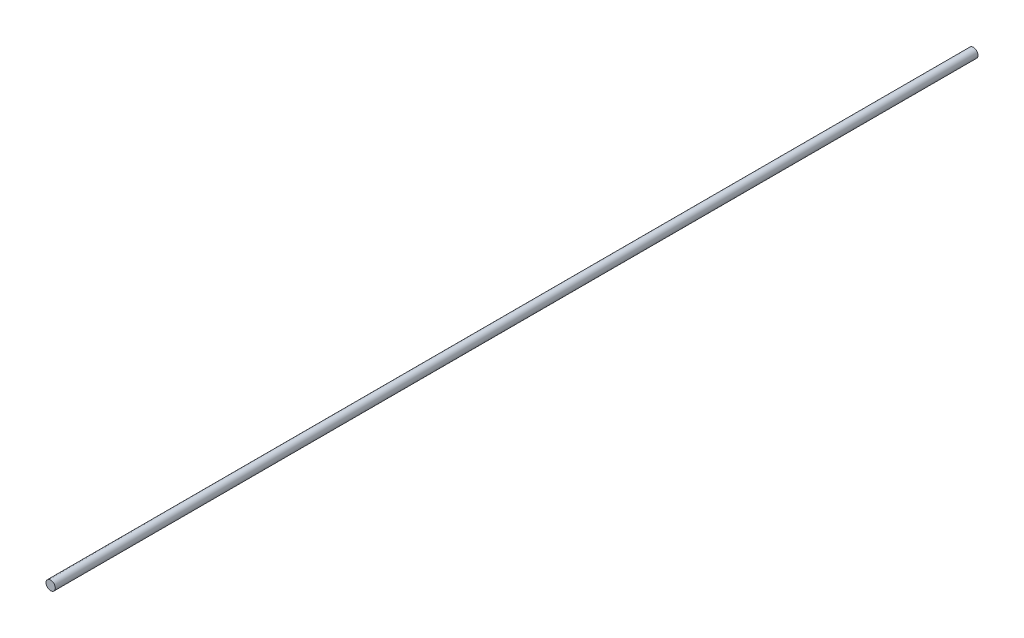
from build123d import *

# Parameters (mm, degrees)
SKETCH1_R           = 1.5875
BOSS_EXTRUDE1_DEPTH = 315.468


with BuildPart() as part:
    # Sketch1 → Boss-Extrude1 (new body)
    with BuildSketch(Plane.XY):
        Circle(SKETCH1_R)
    extrude(amount=BOSS_EXTRUDE1_DEPTH)


solid = part.part
